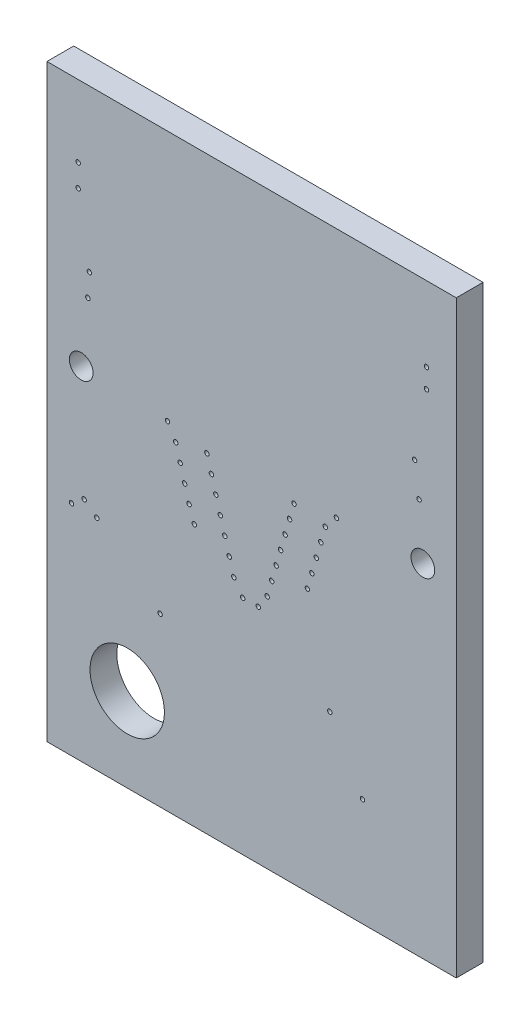
from build123d import *

# Parameters (mm, degrees)
SKETCH1_W           = 13.97
SKETCH1_H           = 20.1041
BOARD_OUTLINE_DEPTH = 0.9144
SKETCH2_R           = 0.0762
NPTH_DEPTH          = 1.9144
SKETCH3_R           = 0.405
SKETCH3_R_2         = 1.27
PTH_DEPTH           = 1.9144


with BuildPart() as part:
    # Sketch1 → Board_Outline (new body)
    with BuildSketch(Plane.XY):
        with Locations((6.985, 10.05205)):
            Rectangle(SKETCH1_W, SKETCH1_H)
    extrude(amount=BOARD_OUTLINE_DEPTH)

    # Sketch2 → NPTH (cut, through all)
    with BuildSketch(Plane.XY):
        with Locations((10.7696, 3.683)):
            Circle(SKETCH2_R)
        with Locations((12.954, 16.891)):
            Circle(SKETCH2_R)
        with Locations((1.0668, 17.653)):
            Circle(SKETCH2_R)
        with Locations((1.4478, 14.605)):
            Circle(SKETCH2_R)
        with Locations((1.397, 13.8176)):
            Circle(SKETCH2_R)
        with Locations((4.1148, 11.5316)):
            Circle(SKETCH2_R)
        with Locations((4.3942, 11.049)):
            Circle(SKETCH2_R)
        with Locations((4.5466, 10.5156)):
            Circle(SKETCH2_R)
        with Locations((4.699, 9.9822)):
            Circle(SKETCH2_R)
        with Locations((4.8514, 9.4488)):
            Circle(SKETCH2_R)
        with Locations((5.0292, 8.9408)):
            Circle(SKETCH2_R)
        with Locations((5.461, 11.2522)):
            Circle(SKETCH2_R)
        with Locations((5.6134, 10.7188)):
            Circle(SKETCH2_R)
        with Locations((5.7658, 10.1854)):
            Circle(SKETCH2_R)
        with Locations((5.9182, 9.652)):
            Circle(SKETCH2_R)
        with Locations((6.0706, 9.1186)):
            Circle(SKETCH2_R)
        with Locations((6.223, 8.5852)):
            Circle(SKETCH2_R)
        with Locations((6.3754, 8.0518)):
            Circle(SKETCH2_R)
        with Locations((6.6802, 7.5946)):
            Circle(SKETCH2_R)
        with Locations((12.5476, 14.605)):
            Circle(SKETCH2_R)
        with Locations((12.7, 13.5128)):
            Circle(SKETCH2_R)
        with Locations((9.8806, 11.557)):
            Circle(SKETCH2_R)
        with Locations((9.4996, 11.0998)):
            Circle(SKETCH2_R)
        with Locations((9.3472, 10.5664)):
            Circle(SKETCH2_R)
        with Locations((9.1948, 10.033)):
            Circle(SKETCH2_R)
        with Locations((9.0424, 9.4996)):
            Circle(SKETCH2_R)
        with Locations((8.89, 8.9662)):
            Circle(SKETCH2_R)
        with Locations((8.4328, 11.2522)):
            Circle(SKETCH2_R)
        with Locations((8.2804, 10.7188)):
            Circle(SKETCH2_R)
        with Locations((8.128, 10.1854)):
            Circle(SKETCH2_R)
        with Locations((7.9756, 9.652)):
            Circle(SKETCH2_R)
        with Locations((7.8232, 9.1186)):
            Circle(SKETCH2_R)
        with Locations((7.6708, 8.5852)):
            Circle(SKETCH2_R)
        with Locations((7.5184, 8.0518)):
            Circle(SKETCH2_R)
        with Locations((7.2136, 7.5946)):
            Circle(SKETCH2_R)
        with Locations((1.7018, 7.4676)):
            Circle(SKETCH2_R)
        with Locations((1.27, 7.7978)):
            Circle(SKETCH2_R)
        with Locations((0.8382, 7.4676)):
            Circle(SKETCH2_R)
        with Locations((12.954, 17.5514)):
            Circle(SKETCH2_R)
        with Locations((1.0668, 16.891)):
            Circle(SKETCH2_R)
        with Locations((9.652, 5.715)):
            Circle(SKETCH2_R)
        with Locations((3.8608, 5.715)):
            Circle(SKETCH2_R)
    extrude(amount=NPTH_DEPTH, mode=Mode.SUBTRACT)

    # Sketch3 → PTH (cut, through all)
    with BuildSketch(Plane.XY):
        with Locations((12.83, 11.68)):
            Circle(SKETCH3_R)
        with Locations((2.74, 2.87)):
            Circle(SKETCH3_R_2)
        with Locations((1.17, 11.68)):
            Circle(SKETCH3_R)
    extrude(amount=PTH_DEPTH, mode=Mode.SUBTRACT)


solid = part.part
